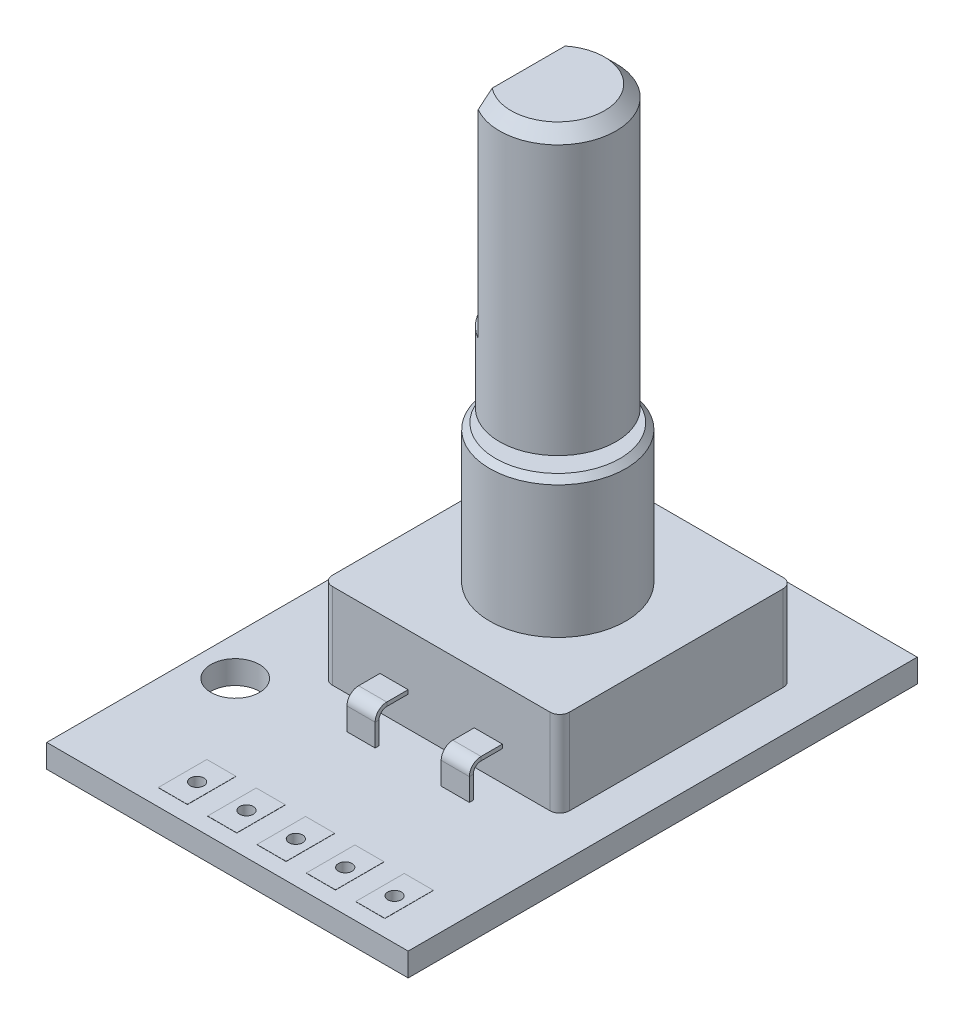
from build123d import *

# Parameters (mm, degrees)
SKETCH1_W           = 18.6
SKETCH1_H           = 26.2
SKETCH1_R           = 1.25
BOSS_EXTRUDE1_DEPTH = 1.2
SKETCH3_W           = 12.2
SKETCH3_H           = 12
BOSS_EXTRUDE2_DEPTH = 4.4
SKETCH10_W          = 1.45
SKETCH10_H          = 0.2
SKETCH13_W          = 1.45
SKETCH13_H          = 0.2
LPATTERN1_COUNT     = 2
LPATTERN1_PITCH     = 2.85
LPATTERN2_COUNT     = 2
LPATTERN2_PITCH     = 2.85
SKETCH14_R          = 3.5
BOSS_EXTRUDE4_DEPTH = 7.1
CHAMFER1_SIZE       = 0.3
SKETCH15_R          = 1.9
BOSS_EXTRUDE5_DEPTH = 0.65
SKETCH16_R          = 3
BOSS_EXTRUDE6_DEPTH = 14.45
CHAMFER2_SIZE       = 0.6
CUT_EXTRUDE1_DEPTH  = 10.8
SKETCH18_R          = 0.35
CUT_EXTRUDE2_DEPTH  = 1.2
SKETCH19_W          = 1.5
SKETCH19_H          = 2.5
SKETCH19_R          = 0.35
BOSS_EXTRUDE7_DEPTH = 0.01
FILLET1_R           = 0.5


with BuildPart() as part:
    # Sketch1 → Boss-Extrude1 (new body)
    with BuildSketch(Plane(origin=(0, 0, 0), x_dir=(1, 0, 0), z_dir=(0, 1, 0))):
        Rectangle(SKETCH1_W, SKETCH1_H)
        with Locations((-7.3, 8.3)):
            Circle(SKETCH1_R, mode=Mode.SUBTRACT)
        with Locations((-7.3, -5.4)):
            Circle(SKETCH1_R, mode=Mode.SUBTRACT)
    extrude(amount=BOSS_EXTRUDE1_DEPTH)

    # Sketch3 → Boss-Extrude2 (add)
    with BuildSketch(Plane(origin=(0, 1.2, 0), x_dir=(1, 0, 0), z_dir=(0, 1, 0))):
        with Locations((1.1, 2.8)):
            Rectangle(SKETCH3_W, SKETCH3_H)
    extrude(amount=BOSS_EXTRUDE2_DEPTH)

    # Sweep3: sweep along a curve in space
    with BuildLine() as sweep3_path:
        Line((-1.325, 2.85, 3.2), (-1.325, 2.85, 4.3))
        ThreePointArc((-1.325, 2.85, 4.3), (-1.325, 2.703553391, 4.653553391), (-1.325, 2.35, 4.8))
        Line((-1.325, 2.35, 4.8), (-1.325, 1.2, 4.8))
    # Sketch10 → Sweep3 (sweep)
    with BuildSketch(Plane.XY.offset(3.2)):
        with Locations((-1.325, 2.85)):
            Rectangle(SKETCH10_W, SKETCH10_H)
    sweep3 = sweep(path=sweep3_path.line)

    # Mirror2: Sweep3 across plane
    add(sweep3.mirror(Plane.ZY.offset(-1.1)))

    # Sweep4: sweep along a curve in space
    with BuildLine() as sweep4_path:
        Line((1.1, 2.8, -8.8), (1.1, 2.8, -9.75))
        ThreePointArc((1.1, 2.8, -9.75), (1.1, 2.653553391, -10.103553391), (1.1, 2.3, -10.25))
        Line((1.1, 2.3, -10.25), (1.1, 1.2, -10.25))
    # Sketch13 → Sweep4 (sweep)
    with BuildSketch(Plane(origin=(0, 0, -8.8), x_dir=(-1, 0, 0), z_dir=(0, 0, -1))):
        with Locations((-1.1, 2.8)):
            Rectangle(SKETCH13_W, SKETCH13_H)
    sweep4 = sweep(path=sweep4_path.line)

    # LPattern1: Sweep4 ×2
    with Locations(*[(-i * LPATTERN1_PITCH, 0, 0) for i in range(1, LPATTERN1_COUNT)]):
        add(sweep4)

    # LPattern2: Sweep4 ×2
    with Locations(*[(i * LPATTERN2_PITCH, 0, 0) for i in range(1, LPATTERN2_COUNT)]):
        add(sweep4)

    # Sketch14 → Boss-Extrude4 (add)
    with BuildSketch(Plane(origin=(0, 5.6, 0), x_dir=(1, 0, 0), z_dir=(0, 1, 0))):
        with Locations((1.1, 2.8)):
            Circle(SKETCH14_R)
    extrude(amount=BOSS_EXTRUDE4_DEPTH)

    # Chamfer1
    chamfer1_edges = [part.edges().sort_by_distance(p)[0] for p in [
        (-2.4, 12.7, -2.8),
    ]]
    chamfer(chamfer1_edges, length=CHAMFER1_SIZE)

    # Sketch15 → Boss-Extrude5 (add)
    with BuildSketch(Plane(origin=(0, 12.7, 0), x_dir=(1, 0, 0), z_dir=(0, 1, 0))):
        with Locations((1.1, 2.8)):
            Circle(SKETCH15_R)
    extrude(amount=BOSS_EXTRUDE5_DEPTH)

    # Sketch16 → Boss-Extrude6 (add)
    with BuildSketch(Plane(origin=(0, 13.35, 0), x_dir=(1, 0, 0), z_dir=(0, 1, 0))):
        with Locations((1.1, 2.8)):
            Circle(SKETCH16_R)
    extrude(amount=BOSS_EXTRUDE6_DEPTH)

    # Chamfer2
    chamfer2_edges = [part.edges().sort_by_distance(p)[0] for p in [
        (-1.9, 27.8, -2.8),
    ]]
    chamfer(chamfer2_edges, length=CHAMFER2_SIZE)

    # Sketch17 → Cut-Extrude1 (cut)
    with BuildSketch(Plane(origin=(0, 27.8, 0), x_dir=(1, 0, 0), z_dir=(0, 1, 0))):
        with BuildLine():
            Line((-0.396662955, 5.4), (-0.396662955, 0.2))
            ThreePointArc((-0.396662955, 0.2), (-1.9, 2.8), (-0.396662955, 5.4))
        make_face()
    extrude(amount=-CUT_EXTRUDE1_DEPTH, mode=Mode.SUBTRACT)

    # Sketch18 → Cut-Extrude2 (cut)
    with BuildSketch(Plane(origin=(0, 1.2, 0), x_dir=(1, 0, 0), z_dir=(0, 1, 0))):
        with Locations((6.5, -11)):
            Circle(SKETCH18_R)
        with Locations((3.96, -11)):
            Circle(SKETCH18_R)
        with Locations((1.42, -11)):
            Circle(SKETCH18_R)
        with Locations((-1.12, -11)):
            Circle(SKETCH18_R)
        with Locations((-3.66, -11)):
            Circle(SKETCH18_R)
    extrude(amount=-CUT_EXTRUDE2_DEPTH, mode=Mode.SUBTRACT)

    # Sketch19 → Boss-Extrude7 (add)
    with BuildSketch(Plane(origin=(0, 1.2, 0), x_dir=(1, 0, 0), z_dir=(0, 1, 0))):
        with Locations((3.96, -11)):
            Rectangle(SKETCH19_W, SKETCH19_H)
        with Locations((3.96, -11)):
            Circle(SKETCH19_R, mode=Mode.SUBTRACT)
        with Locations((6.5, -11)):
            Rectangle(SKETCH19_W, SKETCH19_H)
        with Locations((6.5, -11)):
            Circle(SKETCH19_R, mode=Mode.SUBTRACT)
        with Locations((1.42, -11)):
            Rectangle(SKETCH19_W, SKETCH19_H)
        with Locations((1.42, -11)):
            Circle(SKETCH19_R, mode=Mode.SUBTRACT)
        with Locations((-1.12, -11)):
            Rectangle(SKETCH19_W, SKETCH19_H)
        with Locations((-1.12, -11)):
            Circle(SKETCH19_R, mode=Mode.SUBTRACT)
        with Locations((-3.66, -11)):
            Rectangle(SKETCH19_W, SKETCH19_H)
        with Locations((-3.66, -11)):
            Circle(SKETCH19_R, mode=Mode.SUBTRACT)
    boss_extrude7 = extrude(amount=BOSS_EXTRUDE7_DEPTH)

    # Mirror3: Boss-Extrude7 across plane
    add(boss_extrude7.mirror(Plane.ZX.offset(0.6)))

    # Fillet1
    fillet1_edges = [part.edges().sort_by_distance(p)[0] for p in [
        (7.2, 3.4, 3.2),
        (7.2, 3.4, -8.8),
        (-5, 3.4, -8.8),
        (-5, 3.4, 3.2),
    ]]
    fillet(fillet1_edges, radius=FILLET1_R)


solid = part.part
